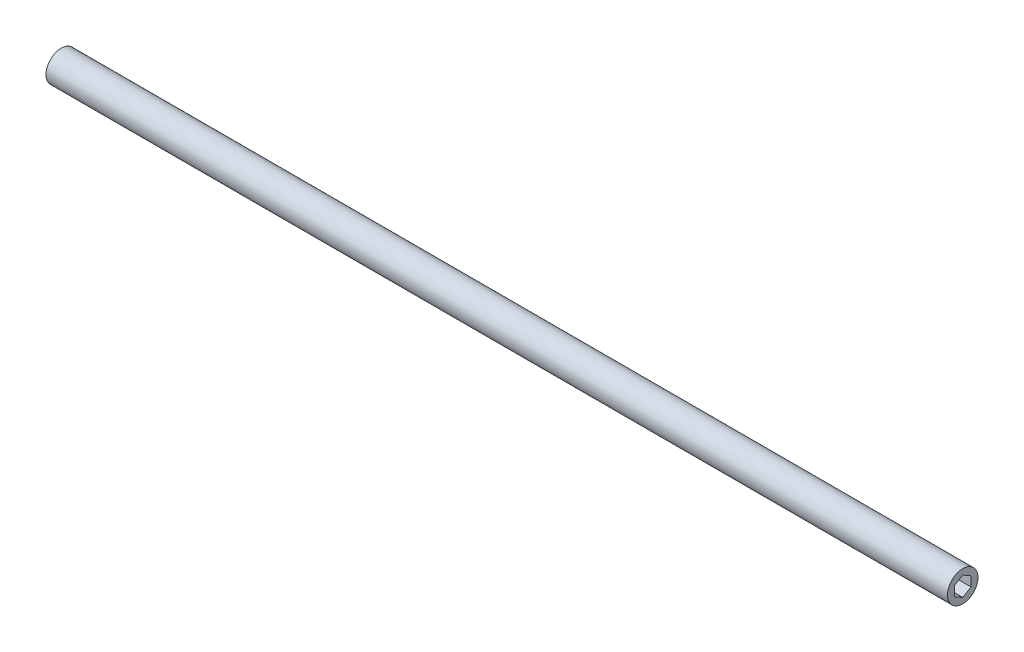
from build123d import *

# Parameters (mm, degrees)
SKETCH1_R           = 11.557
BOSS_EXTRUDE1_DEPTH = 682.625


with BuildPart() as part:
    # Sketch1 → Boss-Extrude1 (new body)
    with BuildSketch(Plane(origin=(0, 0, 0), x_dir=(0, 0, -1), z_dir=(1, 0, 0))):
        Circle(SKETCH1_R)
        Polygon((0, 7.332348419), (-6.35, 3.666174209), (-6.35, -3.666174209), (0, -7.332348419), (6.35, -3.666174209), (6.35, 3.666174209), align=None, mode=Mode.SUBTRACT)
    extrude(amount=BOSS_EXTRUDE1_DEPTH)


solid = part.part
